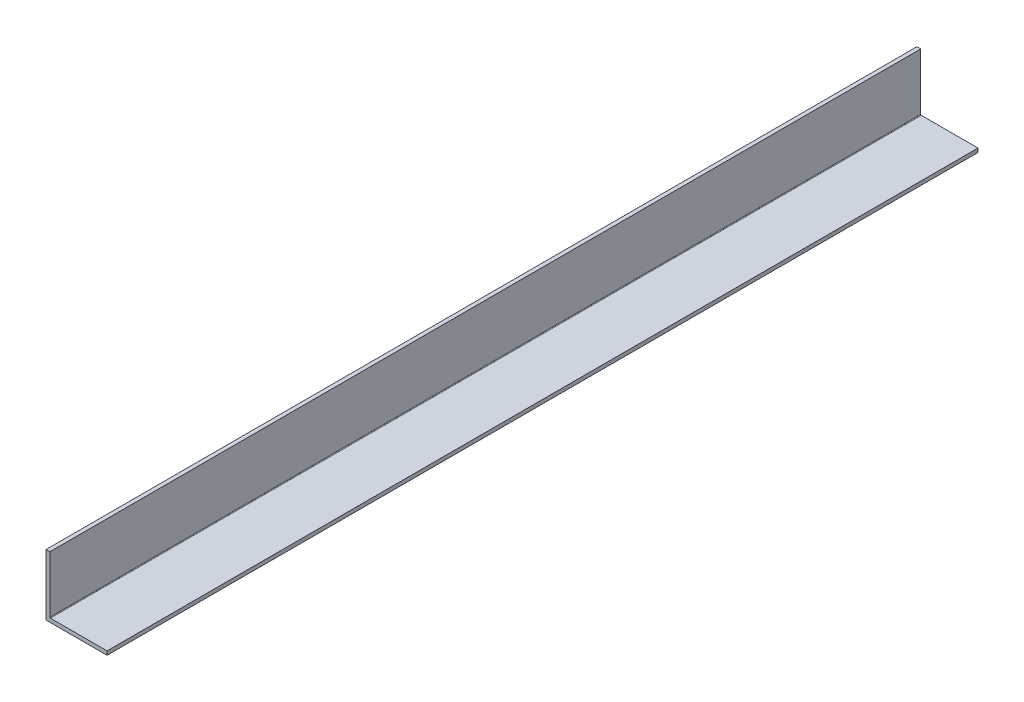
from build123d import *

# Parameters (mm, degrees)
BOSS_EXTRUDE1_DEPTH = 304.8
FILLET1_R           = 0.254
CUT_EXTRUDE1_DEPTH  = 247.35


with BuildPart() as part:
    # Sketch3 → Boss-Extrude1 (new, symmetric)
    with BuildSketch(Plane.XY):
        Polygon((1.5875, 25.4), (0, 25.4), (0, 0), (25.4, 0), (25.4, 1.5875), (1.5875, 1.5875), align=None)
    extrude(amount=BOSS_EXTRUDE1_DEPTH, both=True)

    # Fillet1
    fillet1_edges = [part.edges().sort_by_distance(p)[0] for p in [
        (1.5875, 1.5875, 0),
    ]]
    fillet(fillet1_edges, radius=FILLET1_R)

    # Sketch4 → Cut-Extrude1 (cut)
    with BuildSketch(Plane(origin=(0, 0, -304.8), x_dir=(-1, 0, 0), z_dir=(0, 0, -1))):
        with BuildLine():
            Line((-1.5875, 25.4), (-1.5875, 1.8415))
            ThreePointArc((-1.5875, 1.8415), (-1.661894878, 1.661894878), (-1.8415, 1.5875))
            Line((-1.8415, 1.5875), (-25.4, 1.5875))
            Line((-25.4, 1.5875), (-25.4, 0))
            Line((-25.4, 0), (0, 0))
            Line((0, 0), (0, 25.4))
            Line((0, 25.4), (-1.5875, 25.4))
        make_face()
    extrude(amount=-CUT_EXTRUDE1_DEPTH, mode=Mode.SUBTRACT)


solid = part.part
